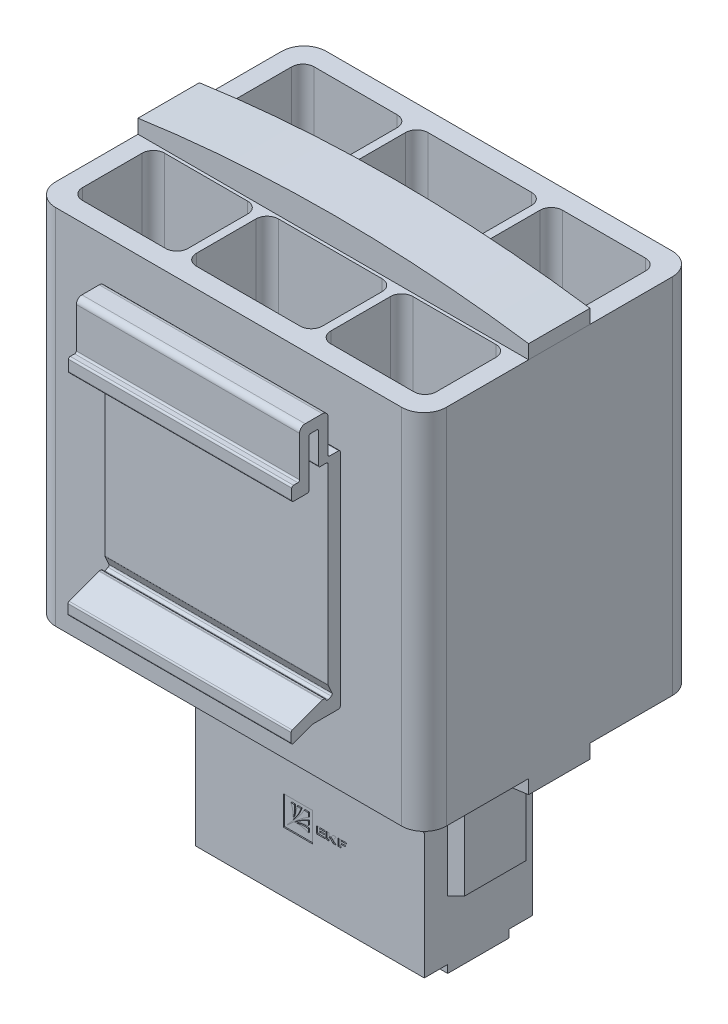
from build123d import *

# Parameters (mm, degrees)
SKETCH_1_W                  = 70
SKETCH_1_H                  = 65
EXTRUDE_1_DEPTH             = 48.5
CUT_EXTRUDE_1_REACH         = 67
SKETCH_2_W                  = 22.6
SKETCH_2_H                  = 14.7
SKETCH_2_W_2                = 18.9
SKETCH_3_W                  = 70
SKETCH_3_H                  = 11
EXTRUDE_2_DEPTH             = 5
CUT_EXTRUDE_4_DEPTH         = 11
EXTRUDE_3_REACH             = 26.25
EXTRUDE_3_DIRECTION_2_REACH = 26.25
EXTRUDE_4_DEPTH             = 4.2
CHAMFER_1_SIZE              = 4
CHAMFER_1_OF_MIRROR_3_SIZE  = 4
SKETCH_7_W                  = 11.3
SKETCH_7_H                  = 8.5
EXTRUDE_5_DEPTH             = 2
EXTRUDE_5_TAPER             = 12
SKETCH_9_W                  = 4
SKETCH_9_H                  = 5
CUT_EXTRUDE_5_DEPTH         = 7
SKETCH_10_W                 = 4
SKETCH_10_H                 = 6
CUT_EXTRUDE_6_DEPTH         = 1.4
EXTRUDE_6_DEPTH             = 20
FILLET_1_R                  = 4
FILLET_2_R                  = 2
SKETCH_12_W                 = 5.218176
SKETCH_12_H                 = 5.208077048
CUT_EXTRUDE_7_DEPTH         = 0.2


with BuildPart() as part:
    # Эскиз1 → Бобышка-Вытянуть1 (new body)
    with BuildSketch(Plane.XY):
        Rectangle(SKETCH_1_W, SKETCH_1_H)
    extrude(amount=EXTRUDE_1_DEPTH)

    # Эскиз2 → Вырез-Вытянуть1 (cut, up to next)
    with BuildSketch(Plane(origin=(0, 32.5, 0), x_dir=(1, 0, 0), z_dir=(0, 1, 0)), mode=Mode.PRIVATE) as cut_extrude_1_sk1:
        with Locations((0, -10.85)):
            Rectangle(SKETCH_2_W, SKETCH_2_H)
    cut_extrude_1_tool1 = extrude(cut_extrude_1_sk1.sketch, amount=-CUT_EXTRUDE_1_REACH, mode=Mode.PRIVATE) & part.part
    add(cut_extrude_1_tool1.solids().sort_by_distance((0, 32.5, 10.85))[0], mode=Mode.SUBTRACT)
    # Эскиз2 → Вырез-Вытянуть1 (cut, up to next)
    with BuildSketch(Plane(origin=(0, 32.5, 0), x_dir=(1, 0, 0), z_dir=(0, 1, 0)), mode=Mode.PRIVATE) as cut_extrude_1_sk2:
        with Locations((22.25, -10.85)):
            Rectangle(SKETCH_2_W_2, SKETCH_2_H)
    cut_extrude_1_tool2 = extrude(cut_extrude_1_sk2.sketch, amount=-CUT_EXTRUDE_1_REACH, mode=Mode.PRIVATE) & part.part
    add(cut_extrude_1_tool2.solids().sort_by_distance((22.25, 32.5, 10.85))[0], mode=Mode.SUBTRACT)
    # Эскиз2 → Вырез-Вытянуть1 (cut, up to next)
    with BuildSketch(Plane(origin=(0, 32.5, 0), x_dir=(1, 0, 0), z_dir=(0, 1, 0)), mode=Mode.PRIVATE) as cut_extrude_1_sk3:
        with Locations((-22.25, -10.85)):
            Rectangle(SKETCH_2_W_2, SKETCH_2_H)
    cut_extrude_1_tool3 = extrude(cut_extrude_1_sk3.sketch, amount=-CUT_EXTRUDE_1_REACH, mode=Mode.PRIVATE) & part.part
    add(cut_extrude_1_tool3.solids().sort_by_distance((-22.25, 32.5, 10.85))[0], mode=Mode.SUBTRACT)
    # Эскиз2 → Вырез-Вытянуть1 (cut, up to next)
    with BuildSketch(Plane(origin=(0, 32.5, 0), x_dir=(1, 0, 0), z_dir=(0, 1, 0)), mode=Mode.PRIVATE) as cut_extrude_1_sk4:
        with Locations((22.25, -37.65)):
            Rectangle(SKETCH_2_W_2, SKETCH_2_H)
    cut_extrude_1_tool4 = extrude(cut_extrude_1_sk4.sketch, amount=-CUT_EXTRUDE_1_REACH, mode=Mode.PRIVATE) & part.part
    add(cut_extrude_1_tool4.solids().sort_by_distance((22.25, 32.5, 37.65))[0], mode=Mode.SUBTRACT)
    # Эскиз2 → Вырез-Вытянуть1 (cut, up to next)
    with BuildSketch(Plane(origin=(0, 32.5, 0), x_dir=(1, 0, 0), z_dir=(0, 1, 0)), mode=Mode.PRIVATE) as cut_extrude_1_sk5:
        with Locations((0, -37.65)):
            Rectangle(SKETCH_2_W, SKETCH_2_H)
    cut_extrude_1_tool5 = extrude(cut_extrude_1_sk5.sketch, amount=-CUT_EXTRUDE_1_REACH, mode=Mode.PRIVATE) & part.part
    add(cut_extrude_1_tool5.solids().sort_by_distance((0, 32.5, 37.65))[0], mode=Mode.SUBTRACT)
    # Эскиз2 → Вырез-Вытянуть1 (cut, up to next)
    with BuildSketch(Plane(origin=(0, 32.5, 0), x_dir=(1, 0, 0), z_dir=(0, 1, 0)), mode=Mode.PRIVATE) as cut_extrude_1_sk6:
        with Locations((-22.25, -37.65)):
            Rectangle(SKETCH_2_W_2, SKETCH_2_H)
    cut_extrude_1_tool6 = extrude(cut_extrude_1_sk6.sketch, amount=-CUT_EXTRUDE_1_REACH, mode=Mode.PRIVATE) & part.part
    add(cut_extrude_1_tool6.solids().sort_by_distance((-22.25, 32.5, 37.65))[0], mode=Mode.SUBTRACT)


with BuildPart() as body_2:
    # Эскиз3 → Бобышка-Вытянуть2 (new body)
    with BuildSketch(Plane(origin=(0, 32.5, 0), x_dir=(1, 0, 0), z_dir=(0, 1, 0))):
        with Locations((0, -24.25)):
            Rectangle(SKETCH_3_W, SKETCH_3_H)
    extrude_2 = extrude(amount=EXTRUDE_2_DEPTH)

    # Эскиз4 → Вырез-Вытянуть4 (cut)
    with BuildSketch(Plane.XY.offset(29.75)):
        with BuildLine():
            Line((-35, 35), (-35, 41))
            Line((-35, 41), (35, 41))
            Line((35, 41), (35, 35))
            ThreePointArc((35, 35), (0, 37.5), (-35, 35))
        make_face()
    cut_extrude_4 = extrude(amount=-CUT_EXTRUDE_4_DEPTH, mode=Mode.SUBTRACT)


with BuildPart() as part_1:
    add(part.part)

    # Зеркальное отражение2: Бобышка-Вытянуть2, Вырез-Вытянуть4 across plane
    add(extrude_2.mirror(Plane.ZX))
    add(cut_extrude_4.mirror(Plane.ZX), mode=Mode.SUBTRACT)

    # Бобышка-Вытянуть3: up to this face of the body (flat: up to its plane)
    extrude_3_end = Plane(part_1.part.faces().sort_by_distance((0, -34.650725053, 18.75))[0])
    # Эскиз5 → Бобышка-Вытянуть3 (add, up to the picked face)
    with BuildSketch(Plane(origin=(0, 0, 24.25), x_dir=(-1, 0, 0), z_dir=(0, 0, -1)), mode=Mode.PRIVATE) as extrude_3_sk1:
        with BuildLine():
            Line((-23.5, -36.3761155), (-23.5, -56.5))
            Line((-23.5, -56.5), (-20.5, -58))
            Line((-20.5, -58), (-20.5, -70))
            Line((-20.5, -70), (20.5, -70))
            Line((20.5, -70), (20.5, -58))
            Line((20.5, -58), (23.5, -56.5))
            Line((23.5, -56.5), (23.5, -36.3761155))
            ThreePointArc((23.5, -36.3761155), (0, -37.5), (-23.5, -36.3761155))
        make_face()
    extrude_3_tool1 = split(extrude(extrude_3_sk1.sketch, amount=EXTRUDE_3_REACH, mode=Mode.PRIVATE), bisect_by=extrude_3_end, keep=Keep.BOTH, mode=Mode.PRIVATE)
    add(extrude_3_tool1.solids().sort_by(Axis((0, -53.0373, 24.25), (0, 0, -1)))[0])

    # Бобышка-Вытянуть3 direction 2: up to this face of the body (flat: up to its plane)
    extrude_3_direction_2_end = Plane(part_1.part.faces().sort_by_distance((0, -34.650725053, 29.75))[0])
    # Эскиз5 → Бобышка-Вытянуть3 direction 2 (add, up to the picked face)
    with BuildSketch(Plane(origin=(0, 0, 24.25), x_dir=(-1, 0, 0), z_dir=(0, 0, -1)), mode=Mode.PRIVATE) as extrude_3_direction_2_sk1:
        with BuildLine():
            Line((-23.5, -36.3761155), (-23.5, -56.5))
            Line((-23.5, -56.5), (-20.5, -58))
            Line((-20.5, -58), (-20.5, -70))
            Line((-20.5, -70), (20.5, -70))
            Line((20.5, -70), (20.5, -58))
            Line((20.5, -58), (23.5, -56.5))
            Line((23.5, -56.5), (23.5, -36.3761155))
            ThreePointArc((23.5, -36.3761155), (0, -37.5), (-23.5, -36.3761155))
        make_face()
    extrude_3_direction_2_tool1 = split(extrude(extrude_3_direction_2_sk1.sketch, amount=-EXTRUDE_3_DIRECTION_2_REACH, mode=Mode.PRIVATE), bisect_by=extrude_3_direction_2_end, keep=Keep.BOTH, mode=Mode.PRIVATE)
    add(extrude_3_direction_2_tool1.solids().sort_by(Axis((0, -53.0373, 24.25), (0, 0, 1)))[0])

    # Эскиз6 → Бобышка-Вытянуть4 (add)
    with BuildSketch(Plane.XY.offset(29.75)):
        with BuildLine():
            Line((-20.5, -68.6), (-20.5, -41.6))
            ThreePointArc((-20.5, -41.6), (0, -36.6), (20.5, -41.6))
            Line((20.5, -41.6), (20.5, -68.6))
            Line((20.5, -68.6), (-20.5, -68.6))
        make_face()
    extrude_4 = extrude(amount=EXTRUDE_4_DEPTH)

    # Фаска1
    chamfer_1_edges = [part_1.edges().sort_by_distance(p)[0] for p in [
        (0, -36.6, 33.95),
    ]]
    chamfer(chamfer_1_edges, length=CHAMFER_1_SIZE)

    # Зеркальное отражение3: Бобышка-Вытянуть4 across plane
    add(extrude_4.mirror(Plane(origin=(0, 0, 24.25), x_dir=(1, 0, 0), z_dir=(0, 0, -1))))

    # Фаска1 of Зеркальное отражение3
    chamfer_1_of_mirror_3_edges = [part_1.edges().sort_by_distance(p)[0] for p in [
        (0, -36.6, 14.55),
    ]]
    chamfer(chamfer_1_of_mirror_3_edges, length=CHAMFER_1_OF_MIRROR_3_SIZE)

    # Эскиз7 → Бобышка-Вытянуть5 (add)
    with BuildSketch(Plane(origin=(0, 0, 14.55), x_dir=(-1, 0, 0), z_dir=(0, 0, -1))):
        with Locations((0, -61.65)):
            Rectangle(SKETCH_7_W, SKETCH_7_H)
        with Locations((-12.5, -61.65)):
            Rectangle(SKETCH_7_W, SKETCH_7_H)
        with Locations((12.5, -61.65)):
            Rectangle(SKETCH_7_W, SKETCH_7_H)
    extrude(amount=EXTRUDE_5_DEPTH, taper=EXTRUDE_5_TAPER)

    # Эскиз9 → Вырез-Вытянуть5 (cut)
    with BuildSketch(Plane.XZ.offset(70)):
        with Locations((-12.5, 27.25)):
            Rectangle(SKETCH_9_W, SKETCH_9_H)
        with Locations((0, 27.25)):
            Rectangle(SKETCH_9_W, SKETCH_9_H)
        with Locations((12.5, 27.25)):
            Rectangle(SKETCH_9_W, SKETCH_9_H)
    extrude(amount=-CUT_EXTRUDE_5_DEPTH, mode=Mode.SUBTRACT)

    # Эскиз10 → Вырез-Вытянуть6 (cut)
    with BuildSketch(Plane.XZ.offset(70)):
        with Locations((-12.5, 21.75)):
            Rectangle(SKETCH_10_W, SKETCH_10_H)
        with Locations((0, 21.75)):
            Rectangle(SKETCH_10_W, SKETCH_10_H)
        with Locations((12.5, 21.75)):
            Rectangle(SKETCH_10_W, SKETCH_10_H)
    extrude(amount=-CUT_EXTRUDE_6_DEPTH, mode=Mode.SUBTRACT)

    # Эскиз11 → Бобышка-Вытянуть6 (add, symmetric)
    with BuildSketch(Plane.ZY):
        with BuildLine():
            Line((48.8, -19.7), (53.446494712, -19.7))
            ThreePointArc((53.446494712, -19.7), (53.499168801, -19.704660466), (53.550206319, -19.718497065))
            Line((53.550206319, -19.718497065), (56.896288392, -20.951264145))
            ThreePointArc((56.896288392, -20.951264145), (57.171590381, -20.915844003), (57.3, -20.66976121))
            Line((57.3, -20.66976121), (57.3, -19.071198836))
            ThreePointArc((57.3, -19.071198836), (57.246082793, -18.899608455), (57.103711608, -18.789695901))
            Line((57.103711608, -18.789695901), (51.753314767, -16.818497065))
            ThreePointArc((51.753314767, -16.818497065), (51.702277249, -16.804660466), (51.649603159, -16.8))
            Line((51.649603159, -16.8), (51.395615132, -16.8))
            ThreePointArc((51.395615132, -16.8), (51.233596615, -16.847512377), (51.122897329, -16.975))
            Line((51.122897329, -16.975), (51.053098899, -17.127282197))
            ThreePointArc((51.053098899, -17.127282197), (50.884833356, -17.283511153), (50.655381096, -17.275))
            Line((50.655381096, -17.275), (50.10994549, -17.025))
            ThreePointArc((50.10994549, -17.025), (49.953716535, -16.856734457), (49.962227687, -16.627282197))
            Line((49.962227687, -16.627282197), (50.672717803, -15.077175771))
            ThreePointArc((50.672717803, -15.077175771), (50.693100103, -15.016147089), (50.7, -14.952175771))
            Line((50.7, -14.952175771), (50.7, 19.3))
            ThreePointArc((50.7, 19.3), (50.787867966, 19.512132034), (51, 19.6))
            Line((51, 19.6), (52.1, 19.6))
            ThreePointArc((52.1, 19.6), (52.312132034, 19.687867966), (52.4, 19.9))
            Line((52.4, 19.9), (52.4, 25.3))
            ThreePointArc((52.4, 25.3), (52.487867966, 25.512132034), (52.7, 25.6))
            Line((52.7, 25.6), (53.8, 25.6))
            ThreePointArc((53.8, 25.6), (54.012132034, 25.512132034), (54.1, 25.3))
            Line((54.1, 25.3), (54.1, 16.9))
            ThreePointArc((54.1, 16.9), (54.187867966, 16.687867966), (54.4, 16.6))
            Line((54.4, 16.6), (56.9, 16.6))
            ThreePointArc((56.9, 16.6), (57.112132034, 16.687867966), (57.2, 16.9))
            Line((57.2, 16.9), (57.2, 18.8))
            ThreePointArc((57.2, 18.8), (57.112132034, 19.012132034), (56.9, 19.1))
            Line((56.9, 19.1), (56.1, 19.1))
            ThreePointArc((56.1, 19.1), (55.887867966, 19.187867966), (55.8, 19.4))
            Line((55.8, 19.4), (55.8, 26.6))
            ThreePointArc((55.8, 26.6), (55.507106781, 27.307106781), (54.8, 27.6))
            Line((54.8, 27.6), (51.7, 27.6))
            ThreePointArc((51.7, 27.6), (50.992893219, 27.307106781), (50.7, 26.6))
            Line((50.7, 26.6), (50.7, 20.7))
            ThreePointArc((50.7, 20.7), (50.612132034, 20.487867966), (50.4, 20.4))
            Line((50.4, 20.4), (48.8, 20.4))
            ThreePointArc((48.8, 20.4), (48.587867966, 20.312132034), (48.5, 20.1))
            Line((48.5, 20.1), (48.5, -19.4))
            ThreePointArc((48.5, -19.4), (48.587867966, -19.612132034), (48.8, -19.7))
        make_face()
    extrude(amount=EXTRUDE_6_DEPTH, both=True)

    # Скругление1
    fillet_1_edges = [part_1.edges().sort_by_distance(p)[0] for p in [
        (-35, 0, 48.5),
        (35, 0, 48.5),
        (-35, 0, 0),
        (35, 0, 0),
    ]]
    fillet(fillet_1_edges, radius=FILLET_1_R)

    # Скругление2
    fillet_2_edges = [part_1.edges().sort_by_distance(p)[0] for p in [
        (31.7, 0, 3.5),
        (31.7, 0, 18.2),
        (12.8, 0, 18.2),
        (12.8, 0, 3.5),
        (-12.8, 0, 3.5),
        (-12.8, 0, 18.2),
        (-31.7, 0, 18.2),
        (-31.7, 0, 3.5),
        (12.8, 0, 45),
        (12.8, 0, 30.3),
        (31.7, 0, 30.3),
        (31.7, 0, 45),
        (-11.3, 0, 45),
        (-11.3, 0, 30.3),
        (11.3, 0, 30.3),
        (11.3, 0, 45),
        (-31.7, 0, 45),
        (-31.7, 0, 30.3),
        (-12.8, 0, 30.3),
        (-12.8, 0, 45),
        (11.3, 0, 3.5),
        (11.3, 0, 18.2),
        (-11.3, 0, 18.2),
        (-11.3, 0, 3.5),
    ]]
    fillet(fillet_2_edges, radius=FILLET_2_R)

    # Эскиз12 → Вырез-Вытянуть7 (cut)
    with BuildSketch(Plane.XY.offset(33.95)):
        with Locations((-2.153194869, -55.200816307)):
            Rectangle(SKETCH_12_W, SKETCH_12_H)
        with BuildLine():
            Line((-0.287844665, -56.472364172), (-0.287844665, -55.815724172))
            add(Edge.make_bspline(
                [(-0.287844665, -55.815724172), (-0.364066207, -55.803231294), (-0.498455301, -55.796747186), (-0.699199234, -55.788201496), (-0.882339478, -55.778149895), (-1.078532709, -55.777503324), (-1.27801466, -55.79026259), (-1.493103022, -55.80380504), (-1.702130648, -55.830131071), (-1.895028145, -55.867004545), (-2.089624668, -55.906856944), (-2.214462738, -55.955251956), (-2.289080991, -55.974095616)],
                knots=[0, 0, 0, 0, 0.114392782, 0.199276958, 0.29813186, 0.386383771, 0.4900416, 0.594519142, 0.706019229, 0.802156816, 0.885931476, 1, 1, 1, 1], degree=3, weights=[1, 1, 1, 1, 1, 1, 1, 1, 1, 1, 1, 1, 1]))
            ThreePointArc((-2.289080991, -55.974095616), (-2.305002403, -55.98465004), (-2.310817525, -56.002845413))
            add(Edge.make_bspline(
                [(-2.310817525, -56.002845413), (-2.310742641, -56.005453952), (-2.310447399, -56.008312196), (-2.310088634, -56.011189209), (-2.31005867, -56.011425399)],
                knots=[0, 0, 0, 0, 0.917924721, 1, 1, 1, 1], degree=3, weights=[1, 1, 1, 1, 1]))
            ThreePointArc((-2.31005867, -56.011425399), (-2.2999564, -56.029899341), (-2.279982443, -56.03656143))
            add(Edge.make_bspline(
                [(-2.279982443, -56.03656143), (-2.15783672, -56.03016878), (-1.964183513, -56.024731701), (-1.706235052, -56.042927172), (-1.515190658, -56.076438231), (-1.33156933, -56.103311597), (-1.155543255, -56.144712626), (-0.980162801, -56.184148701), (-0.824512335, -56.239798151), (-0.682071698, -56.288631598), (-0.558615048, -56.342406898), (-0.428012123, -56.402734939), (-0.33782853, -56.443140607), (-0.287844665, -56.472364172)],
                knots=[0, 0, 0, 0, 0.177779843, 0.281266765, 0.375033351, 0.459575593, 0.550812921, 0.637750591, 0.720424484, 0.790855402, 0.856523119, 0.915971268, 1, 1, 1, 1], degree=3, weights=[1, 1, 1, 1, 1, 1, 1, 1, 1, 1, 1, 1, 1, 1]))
        make_face(mode=Mode.SUBTRACT)
        with BuildLine():
            Line((-0.287844665, -55.357554649), (-0.287844665, -54.608754649))
            add(Edge.make_bspline(
                [(-0.287844665, -54.608754649), (-0.532911921, -54.692474114), (-0.884052791, -54.859928117), (-1.350459705, -55.091630253), (-1.671762172, -55.289540442), (-1.972476481, -55.479621795), (-2.221404024, -55.650706109), (-2.426579949, -55.795777571), (-2.582058819, -55.920995679), (-2.68340551, -55.988896829), (-2.727259263, -56.026250337)],
                knots=[0, 0, 0, 0, 0.273617521, 0.411874253, 0.551161094, 0.673016205, 0.788625877, 0.871077777, 0.9390107, 1, 1, 1, 1], degree=3, weights=[1, 1, 1, 1, 1, 1, 1, 1, 1, 1, 1]))
            ThreePointArc((-2.727259263, -56.026250337), (-2.733034282, -56.032955127), (-2.736501058, -56.041096781))
            add(Edge.make_bspline(
                [(-2.736501058, -56.041096781), (-2.739253558, -56.051952729), (-2.741033704, -56.07854063), (-2.715851005, -56.085319189), (-2.705149324, -56.085299731)],
                knots=[0, 0, 0, 0, 0.510001267, 1, 1, 1, 1], degree=3, weights=[1, 1, 1, 1, 1]))
            ThreePointArc((-2.705149324, -56.085299731), (-2.697571843, -56.084270724), (-2.69053228, -56.081283814))
            add(Edge.make_bspline(
                [(-2.69053228, -56.081283814), (-2.583930509, -56.018187349), (-2.404932681, -55.925623044), (-2.150970303, -55.800240512), (-1.930122857, -55.702716204), (-1.694372243, -55.618595587), (-1.451522412, -55.539846884), (-1.199446229, -55.481609878), (-0.957708757, -55.435024915), (-0.739187409, -55.399760676), (-0.519055823, -55.377294154), (-0.372602519, -55.365832938), (-0.287844665, -55.357554649)],
                knots=[0, 0, 0, 0, 0.146582667, 0.238455738, 0.335283013, 0.432158166, 0.534640723, 0.637314837, 0.738125498, 0.826096788, 0.899195026, 1, 1, 1, 1], degree=3, weights=[1, 1, 1, 1, 1, 1, 1, 1, 1, 1, 1, 1, 1]))
        make_face(mode=Mode.SUBTRACT)
        with BuildLine():
            Line((-0.287844665, -54.084557239), (-0.287844665, -53.335757239))
            Line((-0.287844665, -53.335757239), (-1.036644665, -53.335757239))
            add(Edge.make_bspline(
                [(-1.036644665, -53.335757239), (-1.082961654, -53.446203104), (-1.175340909, -53.613098597), (-1.319719544, -53.843636613), (-1.45210689, -54.036335512), (-1.592851996, -54.238837015), (-1.741797645, -54.440511202), (-1.898838041, -54.653670107), (-2.073203693, -54.866267541), (-2.248308198, -55.079228122), (-2.415602028, -55.277163885), (-2.56818679, -55.45895171), (-2.723723072, -55.626053909), (-2.914009622, -55.830396645), (-3.343660306, -56.286713993), (-3.710331729, -56.69588113), (-4.003530906, -56.996146894)],
                knots=[0, 0, 0, 0, 0.075851156, 0.120865908, 0.17257577, 0.224174917, 0.277338376, 0.331655611, 0.392142147, 0.451757205, 0.506604808, 0.556595527, 0.602323198, 0.651422593, 0.73377942, 1, 1, 1, 1], degree=3, weights=[1, 1, 1, 1, 1, 1, 1, 1, 1, 1, 1, 1, 1, 1, 1, 1, 1]))
            ThreePointArc((-4.003530906, -56.996146894), (-3.996360801, -57.05153132), (-3.940976375, -57.044361214))
            add(Edge.make_bspline(
                [(-3.940976375, -57.044361214), (-3.64293485, -56.753732706), (-3.236340921, -56.389256171), (-2.782484071, -55.961922196), (-2.578141335, -55.771635646), (-2.411039136, -55.616099364), (-2.229251311, -55.463514602), (-2.031315548, -55.296220772), (-1.818354967, -55.121116267), (-1.605757533, -54.946750615), (-1.392598628, -54.789710219), (-1.190924441, -54.64076457), (-0.988422938, -54.500019464), (-0.795724039, -54.367632119), (-0.565186023, -54.223253483), (-0.39829053, -54.130874228), (-0.287844665, -54.084557239)],
                knots=[0, 0, 0, 0, 0.264643753, 0.347177557, 0.396382463, 0.442208398, 0.492306543, 0.547272009, 0.607015175, 0.66763169, 0.722065648, 0.775343351, 0.82705338, 0.878874362, 0.923985847, 1, 1, 1, 1], degree=3, weights=[1, 1, 1, 1, 1, 1, 1, 1, 1, 1, 1, 1, 1, 1, 1, 1, 1]))
        make_face(mode=Mode.SUBTRACT)
        with BuildLine():
            Line((-1.560842075, -53.335757239), (-2.309642075, -53.335757239))
            add(Edge.make_bspline(
                [(-2.309642075, -53.335757239), (-2.317920364, -53.420515093), (-2.32938158, -53.566968397), (-2.351848102, -53.787099983), (-2.387112341, -54.005621331), (-2.433697304, -54.247358803), (-2.49193431, -54.499434986), (-2.570683013, -54.742284817), (-2.65480363, -54.978035431), (-2.752327938, -55.198882877), (-2.87771047, -55.452845255), (-2.970274775, -55.631843083), (-3.03337124, -55.738444854)],
                knots=[0, 0, 0, 0, 0.100804974, 0.173903212, 0.261874502, 0.362685163, 0.465359277, 0.567841834, 0.664716987, 0.761544262, 0.853417333, 1, 1, 1, 1], degree=3, weights=[1, 1, 1, 1, 1, 1, 1, 1, 1, 1, 1, 1, 1]))
            ThreePointArc((-3.03337124, -55.738444854), (-3.03635815, -55.745484417), (-3.037387157, -55.753061898))
            add(Edge.make_bspline(
                [(-3.037387157, -55.753061898), (-3.037406615, -55.763763579), (-3.030628056, -55.788946278), (-3.004040155, -55.787166132), (-2.993184207, -55.784413632)],
                knots=[0, 0, 0, 0, 0.489998733, 1, 1, 1, 1], degree=3, weights=[1, 1, 1, 1, 1]))
            ThreePointArc((-2.993184207, -55.784413632), (-2.985042554, -55.780946856), (-2.978337763, -55.775171837))
            add(Edge.make_bspline(
                [(-2.978337763, -55.775171837), (-2.940984255, -55.731318084), (-2.873083105, -55.629971393), (-2.747864997, -55.474492523), (-2.602793535, -55.269316598), (-2.431709221, -55.020389055), (-2.241627868, -54.719674746), (-2.043717679, -54.398372279), (-1.812015543, -53.931965365), (-1.64456154, -53.580824495), (-1.560842075, -53.335757239)],
                knots=[0, 0, 0, 0, 0.0609893, 0.128922223, 0.211374123, 0.326983795, 0.448838906, 0.588125747, 0.726382479, 1, 1, 1, 1], degree=3, weights=[1, 1, 1, 1, 1, 1, 1, 1, 1, 1, 1]))
        make_face(mode=Mode.SUBTRACT)
        with BuildLine():
            Line((-2.767811598, -53.335757239), (-3.424451598, -53.335757239))
            add(Edge.make_bspline(
                [(-3.424451598, -53.335757239), (-3.395228033, -53.385741104), (-3.354822365, -53.475924697), (-3.294494324, -53.606527622), (-3.240719024, -53.729984272), (-3.191885577, -53.872424909), (-3.136236127, -54.028075375), (-3.096800052, -54.203455829), (-3.055399023, -54.379481904), (-3.028525657, -54.563103232), (-2.995014598, -54.754147626), (-2.976819127, -55.012096087), (-2.982256206, -55.205749294), (-2.988648856, -55.327895017)],
                knots=[0, 0, 0, 0, 0.084028732, 0.143476881, 0.209144598, 0.279575516, 0.362249409, 0.449187079, 0.540424407, 0.624966649, 0.718733235, 0.822220157, 1, 1, 1, 1], degree=3, weights=[1, 1, 1, 1, 1, 1, 1, 1, 1, 1, 1, 1, 1, 1]))
            ThreePointArc((-2.988648856, -55.327895017), (-2.981986767, -55.347868974), (-2.963512825, -55.357971244))
            add(Edge.make_bspline(
                [(-2.963512825, -55.357971244), (-2.963276635, -55.358001208), (-2.960399622, -55.358359973), (-2.957541379, -55.358655215), (-2.954932839, -55.358730099)],
                knots=[0, 0, 0, 0, 0.082075279, 1, 1, 1, 1], degree=3, weights=[1, 1, 1, 1, 1]))
            ThreePointArc((-2.954932839, -55.358730099), (-2.936737466, -55.352914977), (-2.926183042, -55.336993565))
            add(Edge.make_bspline(
                [(-2.926183042, -55.336993565), (-2.907339383, -55.262375312), (-2.85894437, -55.137537241), (-2.819091971, -54.942940719), (-2.782218497, -54.750043222), (-2.755892466, -54.541015596), (-2.742350016, -54.325927234), (-2.72959075, -54.126445283), (-2.730237321, -53.930252052), (-2.740288922, -53.747111808), (-2.748834612, -53.546367875), (-2.755318721, -53.411978781), (-2.767811598, -53.335757239)],
                knots=[0, 0, 0, 0, 0.114068524, 0.197843184, 0.293980771, 0.405480858, 0.5099584, 0.613616229, 0.70186814, 0.800723042, 0.885607218, 1, 1, 1, 1], degree=3, weights=[1, 1, 1, 1, 1, 1, 1, 1, 1, 1, 1, 1, 1]))
        make_face(mode=Mode.SUBTRACT)
        Polygon((4.995690087, -54.608754649), (4.995690087, -55.878834649), (5.548650087, -55.878834649), (5.548650087, -55.302834649), (6.424170087, -55.302834649), (6.424170087, -55.118514649), (5.548650087, -55.118514649), (5.548650087, -54.801714649), (6.522090087, -54.801714649), (6.522090087, -54.608754649), align=None)
        with BuildLine():
            Line((3.425558963, -55.314551785), (3.575318963, -55.314551785))
            add(Edge.make_bspline(
                [(3.575318963, -55.314551785), (3.610508567, -55.317125361), (3.677065028, -55.330322621), (3.730489243, -55.37197679), (3.74855232, -55.396587623)],
                knots=[0, 0, 0, 0, 0.539815798, 1, 1, 1, 1], degree=3, weights=[1, 1, 1, 1, 1]))
            Line((3.74855232, -55.396587623), (4.125479009, -55.879031785))
            Line((4.125479009, -55.879031785), (4.701479036, -55.879031785))
            Line((4.701479036, -55.879031785), (4.229501268, -55.27492779))
            ThreePointArc((4.229501268, -55.27492779), (4.223395977, -55.257196739), (4.229501268, -55.239465689))
            Line((4.229501268, -55.239465689), (4.719210087, -54.612666984))
            Line((4.719210087, -54.612666984), (4.137968459, -54.612666984))
            Line((4.137968459, -54.612666984), (3.836540601, -54.998477049))
            add(Edge.make_bspline(
                [(3.836540601, -54.998477049), (3.808682549, -55.035491108), (3.784348806, -55.053655178), (3.721180496, -55.100507037), (3.684758963, -55.109874649)],
                knots=[0, 0, 0, 0, 0.375989027, 1, 1, 1, 1], degree=3, weights=[1, 1, 1, 1, 1]))
            Line((3.684758963, -55.109874649), (3.425558963, -55.109874649))
            Line((3.425558963, -55.109874649), (3.425558963, -54.608754649))
            Line((3.425558963, -54.608754649), (2.871385096, -54.608754649))
            Line((2.871385096, -54.608754649), (2.871385096, -55.538886192))
            add(Edge.make_bspline(
                [(2.871385096, -55.538886192), (2.872864656, -55.579141574), (2.883952694, -55.637206375), (2.903254574, -55.712266121), (2.925248369, -55.760180702), (2.953274232, -55.817452342), (2.979730973, -55.8549798), (2.997833011, -55.879031785)],
                knots=[0, 0, 0, 0, 0.326177772, 0.481344246, 0.628374797, 0.754486768, 1, 1, 1, 1], degree=3, weights=[1, 1, 1, 1, 1, 1, 1, 1]))
            Line((2.997833011, -55.879031785), (3.425558963, -55.879031785))
            Line((3.425558963, -55.879031785), (3.425558963, -55.314551785))
        make_face()
        with BuildLine():
            Line((1.712976958, -55.311474649), (2.605776958, -55.311474649))
            Line((2.605776958, -55.311474649), (2.605776958, -55.109874649))
            Line((2.605776958, -55.109874649), (1.712976958, -55.109874649))
            Line((1.712976958, -55.109874649), (1.712976958, -54.810354649))
            Line((1.712976958, -54.810354649), (2.692176958, -54.810354649))
            Line((2.692176958, -54.810354649), (2.692176958, -54.608754649))
            Line((2.692176958, -54.608754649), (1.165776958, -54.608754649))
            Line((1.165776958, -54.608754649), (1.165776958, -55.538886192))
            ThreePointArc((1.165776958, -55.538886192), (1.175181788, -55.642548691), (1.203089158, -55.742826021))
            add(Edge.make_bspline(
                [(1.203089158, -55.742826021), (1.205338582, -55.748767664), (1.216993475, -55.777519704), (1.239687753, -55.818254616), (1.264428202, -55.849978758), (1.274967286, -55.861083376)],
                knots=[0, 0, 0, 0, 0.137107997, 0.669561873, 1, 1, 1, 1], degree=3, weights=[1, 1, 1, 1, 1, 1]))
            ThreePointArc((1.274967286, -55.861083376), (1.294010856, -55.874354803), (1.316746603, -55.879031785))
            Line((1.316746603, -55.879031785), (2.692176958, -55.879031785))
            Line((2.692176958, -55.879031785), (2.692176958, -55.685874649))
            Line((2.692176958, -55.685874649), (1.712976958, -55.685874649))
            Line((1.712976958, -55.685874649), (1.712976958, -55.311474649))
        make_face()
    extrude(amount=-CUT_EXTRUDE_7_DEPTH, mode=Mode.SUBTRACT)


solid = Compound([body_2.part, part_1.part])
